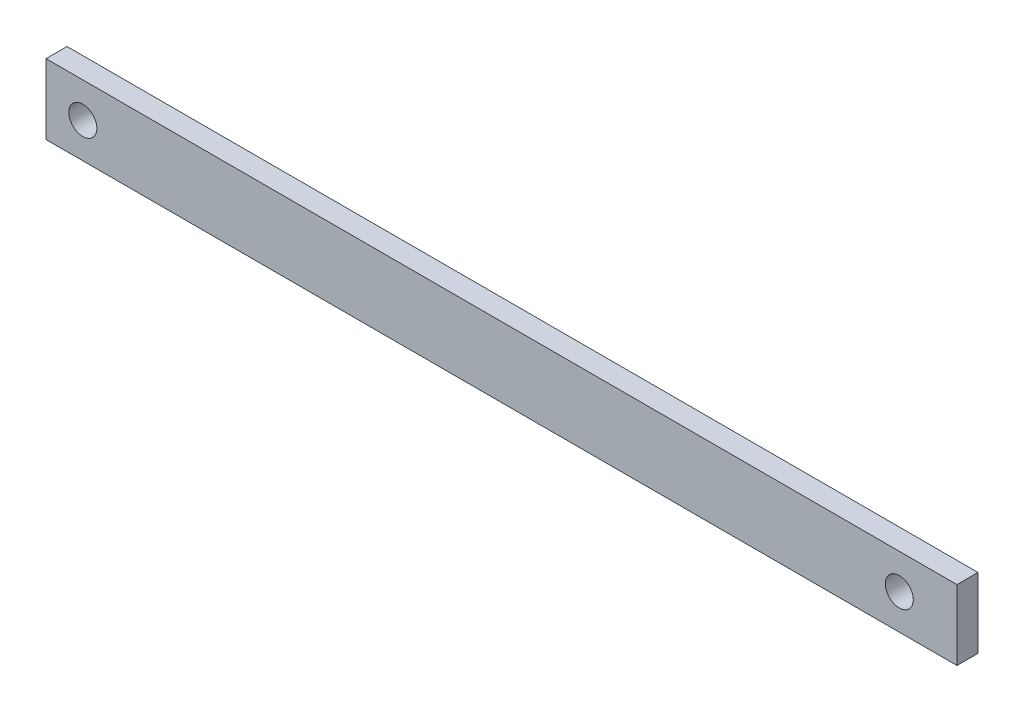
from build123d import *

# Parameters (mm, degrees)
SKETCH1_W           = 130
SKETCH1_H           = 10
BOSS_EXTRUDE1_DEPTH = 3
SKETCH2_R           = 2
CUT_EXTRUDE1_DEPTH  = 10


with BuildPart() as part:
    # Sketch1 → Boss-Extrude1 (new body)
    with BuildSketch(Plane.XY):
        Rectangle(SKETCH1_W, SKETCH1_H)
    extrude(amount=BOSS_EXTRUDE1_DEPTH)

    # Sketch2 → Cut-Extrude1 (cut)
    with BuildSketch(Plane.XY.offset(3)):
        with Locations((-59.74428354, 0)):
            Circle(SKETCH2_R)
        with Locations((56.767577368, 0)):
            Circle(SKETCH2_R)
    extrude(amount=-CUT_EXTRUDE1_DEPTH, mode=Mode.SUBTRACT)


solid = part.part
